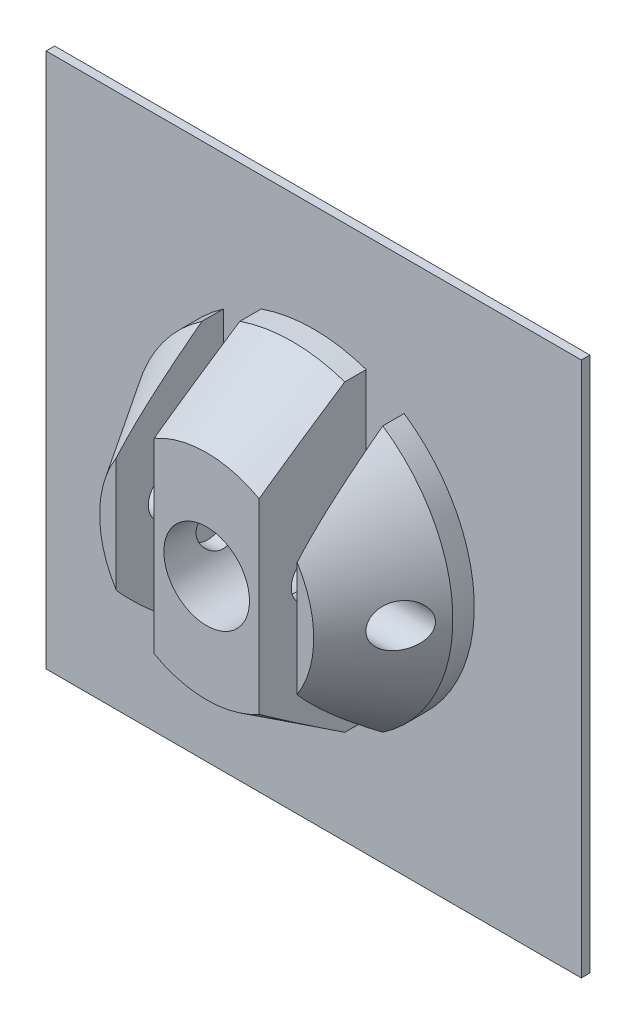
from build123d import *

# Parameters (mm, degrees)
CROQUIS1_W              = 50
CROQUIS1_H              = 50
CROQUIS1_R              = 2
SALIENTE_EXTRUIR2_DEPTH = 0.8
CROQUIS4_R              = 4
CROQUIS4_W              = 3.55
CROQUIS4_H              = 40
CORTAR_EXTRUIR1_DEPTH   = 10
CORTAR_EXTRUIR2_START   = -39.374993
CROQUIS7_R              = 2
CORTAR_EXTRUIR2_DEPTH   = 28.749989
SALIENTE_EXTRUIR4_DEPTH = 10


with BuildPart() as part:
    # Croquis1 → Saliente-Extruir2 (new body)
    with BuildSketch(Plane.XY):
        Rectangle(CROQUIS1_W, CROQUIS1_H)
        Circle(CROQUIS1_R, mode=Mode.SUBTRACT)
    extrude(amount=SALIENTE_EXTRUIR2_DEPTH)

    # Croquis2 → Revolución1 (revolve)
    with BuildSketch(Plane(origin=(0, 0, 0), x_dir=(0, 0, -1), z_dir=(1, 0, 0))):
        Polygon((-0.8, 0), (-10.8, 0), (-10.8, 10), (-2.8, 15), (-0.8, 15), align=None)
    revolve(axis=Axis((0, 0, 0.8), (0, 0, 1)))

    # Croquis4 → Cortar-Extruir1 (cut)
    with BuildSketch(Plane.XY.offset(10.8)):
        Circle(CROQUIS4_R)
        with Locations((-6.675, 0)):
            Rectangle(CROQUIS4_W, CROQUIS4_H)
        with Locations((6.675, 0)):
            Rectangle(CROQUIS4_W, CROQUIS4_H)
    extrude(amount=-CORTAR_EXTRUIR1_DEPTH, mode=Mode.SUBTRACT)

    # Croquis7 → Cortar-Extruir2 (cut)
    with BuildSketch(Plane.ZY.offset(25).offset(CORTAR_EXTRUIR2_START)):
        with Locations((5.8, 0)):
            Circle(CROQUIS7_R)
    extrude(amount=CORTAR_EXTRUIR2_DEPTH, mode=Mode.SUBTRACT)

    # Croquis3 → Saliente-Extruir4 (add)
    with BuildSketch(Plane.XY.offset(0.8)):
        with BuildLine():
            Line((20, -25), (25, -25))
            Line((25, -25), (25, -20))
            ThreePointArc((25, -20), (28.535533906, -28.535533906), (20, -25))
        make_face()
    extrude(amount=SALIENTE_EXTRUIR4_DEPTH)


with BuildPart() as saliente_extruir4_kept_piece:
    # of the separate pieces the step leaves, the one the design keeps (saliente_extruir4_pieces_kept)
    add(part.part.solids().sort_by_distance((25, -25, 0))[0])


solid = saliente_extruir4_kept_piece.part
